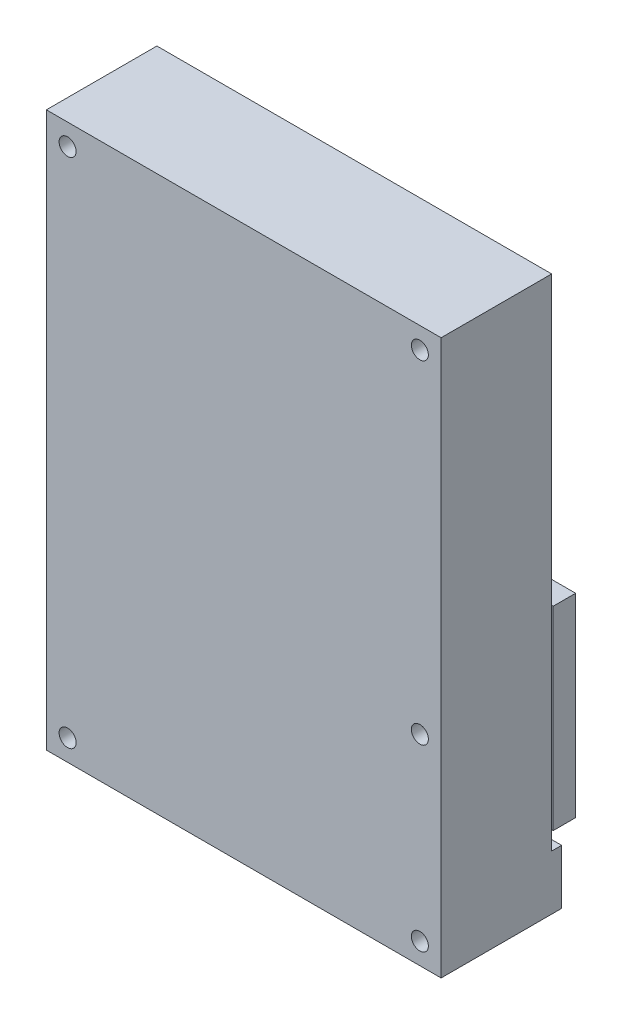
from build123d import *

# Parameters (mm, degrees)
SKETCH1_W            = 65
SKETCH1_H            = 91.3
BOSS_EXTRUDE2_DEPTH  = 18.2
SKETCH12_W           = 65
SKETCH12_H           = 9
BOSS_EXTRUDE7_DEPTH  = 1.64
SKETCH13_W           = 34.2
SKETCH13_H           = 0.25
BOSS_EXTRUDE8_DEPTH  = 5.61
BOSS_EXTRUDE13_DEPTH = 34.2
SKETCH19_W           = 34.2
SKETCH19_H           = 0.25
BOSS_EXTRUDE14_DEPTH = 4.1
SKETCH20_W           = 45.4
SKETCH20_H           = 3.7
BOSS_EXTRUDE15_DEPTH = 32
SKETCH21_R           = 1.4
CUT_EXTRUDE2_DEPTH   = 32
SKETCH22_R           = 1.4
CUT_EXTRUDE3_DEPTH   = 61
SKETCH23_R           = 1.4
CUT_EXTRUDE4_DEPTH   = 61
SKETCH24_R           = 1.4
CUT_EXTRUDE5_DEPTH   = 61
SKETCH25_R           = 1.3
CUT_EXTRUDE6_DEPTH   = 10
SKETCH26_R           = 1.3
CUT_EXTRUDE7_DEPTH   = 10
SKETCH27_R           = 1.4
CUT_EXTRUDE9_DEPTH   = 1500


with BuildPart() as part:
    # Sketch1 → Boss-Extrude2 (new body)
    with BuildSketch(Plane.XY):
        with Locations((1.837659334, -10.779179331)):
            Rectangle(SKETCH1_W, SKETCH1_H)
    extrude(amount=BOSS_EXTRUDE2_DEPTH)

    # Sketch12 → Boss-Extrude7 (add)
    with BuildSketch(Plane(origin=(0, 0, 0), x_dir=(-1, 0, 0), z_dir=(0, 0, -1))):
        with Locations((-1.837659334, -51.929179331)):
            Rectangle(SKETCH12_W, SKETCH12_H)
    extrude(amount=BOSS_EXTRUDE7_DEPTH)

    # Sketch13 → Boss-Extrude8 (add)
    with BuildSketch(Plane.XZ.offset(56.429179331)):
        with Locations((-1.662340666, 3.075)):
            Rectangle(SKETCH13_W, SKETCH13_H)
    extrude(amount=BOSS_EXTRUDE8_DEPTH)

    # Sketch18 → Boss-Extrude13 (add)
    with BuildSketch(Plane.ZY.offset(18.762340666)):
        with BuildLine():
            Line((3.2, -62.039179331), (2.95, -62.039179331))
            ThreePointArc((2.95, -62.039179331), (-5.8, -70.789179331), (-14.55, -62.039179331))
            Line((-14.55, -62.039179331), (-14.8, -62.039179331))
            ThreePointArc((-14.8, -62.039179331), (-5.8, -71.039179331), (3.2, -62.039179331))
        make_face()
    extrude(amount=-BOSS_EXTRUDE13_DEPTH)

    # Sketch19 → Boss-Extrude14 (add)
    with BuildSketch(Plane(origin=(0, -62.039179331, 0), x_dir=(1, 0, 0), z_dir=(0, 1, 0))):
        with Locations((-1.662340666, 14.675)):
            Rectangle(SKETCH19_W, SKETCH19_H)
    extrude(amount=BOSS_EXTRUDE14_DEPTH)

    # Sketch20 → Boss-Extrude15 (add)
    with BuildSketch(Plane(origin=(0, -57.939179331, 0), x_dir=(1, 0, 0), z_dir=(0, 1, 0))):
        with Locations((-1.662340666, 15.4)):
            Rectangle(SKETCH20_W, SKETCH20_H)
    extrude(amount=BOSS_EXTRUDE15_DEPTH)

    # Sketch21 → Cut-Extrude2 (cut)
    with BuildSketch(Plane.XY.offset(18.2)):
        with Locations((30.837659334, 31.370820669)):
            Circle(SKETCH21_R)
    extrude(amount=-CUT_EXTRUDE2_DEPTH, mode=Mode.SUBTRACT)

    # Sketch22 → Cut-Extrude3 (cut)
    with BuildSketch(Plane.XY.offset(18.2)):
        with Locations((-27.162340666, 31.370820669)):
            Circle(SKETCH22_R)
    extrude(amount=-CUT_EXTRUDE3_DEPTH, mode=Mode.SUBTRACT)

    # Sketch23 → Cut-Extrude4 (cut)
    with BuildSketch(Plane.XY.offset(18.2)):
        with Locations((30.837659334, -52.929179331)):
            Circle(SKETCH23_R)
    extrude(amount=-CUT_EXTRUDE4_DEPTH, mode=Mode.SUBTRACT)

    # Sketch24 → Cut-Extrude5 (cut)
    with BuildSketch(Plane.XY.offset(18.2)):
        with Locations((-27.162340666, -52.929179331)):
            Circle(SKETCH24_R)
    extrude(amount=-CUT_EXTRUDE5_DEPTH, mode=Mode.SUBTRACT)

    # Sketch25 → Cut-Extrude6 (cut)
    with BuildSketch(Plane(origin=(0, 0, -17.25), x_dir=(-1, 0, 0), z_dir=(0, 0, -1))):
        with Locations((21.662340666, -39.939179331)):
            Circle(SKETCH25_R)
    extrude(amount=-CUT_EXTRUDE6_DEPTH, mode=Mode.SUBTRACT)

    # Sketch26 → Cut-Extrude7 (cut)
    with BuildSketch(Plane(origin=(0, 0, -17.25), x_dir=(-1, 0, 0), z_dir=(0, 0, -1))):
        with Locations((-18.337659334, -39.939179331)):
            Circle(SKETCH26_R)
    extrude(amount=-CUT_EXTRUDE7_DEPTH, mode=Mode.SUBTRACT)

    # Sketch27 → Cut-Extrude9 (cut)
    with BuildSketch(Plane.XY.offset(18.2)):
        with Locations((30.837659334, -23.429179331)):
            Circle(SKETCH27_R)
    extrude(amount=-CUT_EXTRUDE9_DEPTH, mode=Mode.SUBTRACT)


solid = part.part
